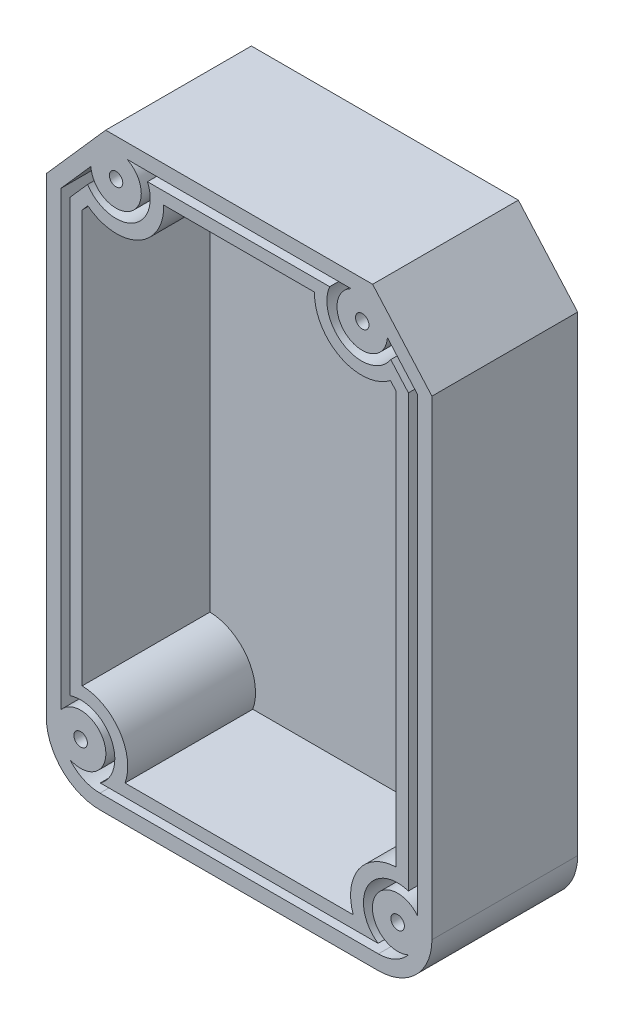
from build123d import *

# Parameters (mm, degrees)
BOSS_EXTRUDE1_DEPTH     = 32.5
CUT_EXTRUDE3_DEPTH      = 1675.790348595
CUT_EXTRUDE3_DEPTH_BACK = 28.5
SKETCH32_R              = 5.625
SKETCH32_R_2            = 1.5
BOSS_EXTRUDE5_DEPTH     = 28.5
CUT_EXTRUDE15_START     = -4
SKETCH33_R              = 1.5
CUT_EXTRUDE15_DEPTH     = 4
BOSS_EXTRUDE6_DEPTH     = 28.5


with BuildPart() as part:
    # Sketch1 → Boss-Extrude1 (new body)
    with BuildSketch(Plane.XY):
        with BuildLine():
            Line((-1355.694223154, -734.745915254), (-1355.694223154, -839.745915254))
            ThreePointArc((-1355.694223154, -839.745915254), (-1359.194004226, -848.195134183), (-1367.643223154, -851.694915254))
            Line((-1367.643223154, -851.694915254), (-1429.745223154, -851.694915254))
            ThreePointArc((-1429.745223154, -851.694915254), (-1438.194442083, -848.195134183), (-1441.694223154, -839.745915254))
            Line((-1441.694223154, -839.745915254), (-1441.694223154, -734.745915254))
            Line((-1441.694223154, -734.745915254), (-1428.465466599, -719.745915254))
            Line((-1428.465466599, -719.745915254), (-1368.92297971, -719.745915254))
            Line((-1368.92297971, -719.745915254), (-1355.694223154, -734.745915254))
        make_face()
    extrude(amount=BOSS_EXTRUDE1_DEPTH)

    # Sketch2 → Cut-Extrude3 (cut, two sides: drawn at the far end of the back side and taken through both)
    with BuildSketch(Plane.XY.offset(32.5).offset(-CUT_EXTRUDE3_DEPTH_BACK)):
        with BuildLine():
            Line((-1358.944223154, -735.974299792), (-1370.390082456, -722.995915254))
            Line((-1370.390082456, -722.995915254), (-1426.998363853, -722.995915254))
            Line((-1426.998363853, -722.995915254), (-1438.444223154, -735.974299792))
            Line((-1438.444223154, -735.974299792), (-1438.444223154, -839.745915254))
            ThreePointArc((-1438.444223154, -839.745915254), (-1435.896345044, -845.897037144), (-1429.745223154, -848.444915254))
            Line((-1429.745223154, -848.444915254), (-1367.643223154, -848.444915254))
            ThreePointArc((-1367.643223154, -848.444915254), (-1361.492101265, -845.897037144), (-1358.944223154, -839.745915254))
            Line((-1358.944223154, -839.745915254), (-1358.944223154, -735.974299792))
        make_face()
    extrude(amount=CUT_EXTRUDE3_DEPTH + CUT_EXTRUDE3_DEPTH_BACK, mode=Mode.SUBTRACT)

    # Sketch32 → Boss-Extrude5 (add)
    # profile 1 of 4: a face of its own
    with BuildSketch(Plane.XY.offset(4)):
        with Locations((-1426.148363853, -728.045915254)):
            Circle(SKETCH32_R)
        with Locations(Location((-1426.148363853, -728.045915254, 0), (0, 0, 180))):
            Circle(SKETCH32_R_2, mode=Mode.SUBTRACT)
    # profile 2 of 4: a face of its own
    with BuildSketch(Plane.XY.offset(4)):
        with Locations((-1371.240082456, -728.045915254)):
            Circle(SKETCH32_R)
        with Locations(Location((-1371.240082456, -728.045915254, 0), (0, 0, 180))):
            Circle(SKETCH32_R_2, mode=Mode.SUBTRACT)
    # profile 3 of 4: a face of its own
    with BuildSketch(Plane.XY.offset(4)):
        with Locations((-1434.045223154, -840.194915254)):
            Circle(SKETCH32_R)
        with Locations(Location((-1434.045223154, -840.194915254, 0), (0, 0, 180))):
            Circle(SKETCH32_R_2, mode=Mode.SUBTRACT)
    # profile 4 of 4: a face of its own
    with BuildSketch(Plane.XY.offset(4)):
        with Locations((-1363.343223154, -840.194915254)):
            Circle(SKETCH32_R)
        with Locations(Location((-1363.343223154, -840.194915254, 0), (0, 0, 180))):
            Circle(SKETCH32_R_2, mode=Mode.SUBTRACT)
    extrude(amount=BOSS_EXTRUDE5_DEPTH)

    # Sketch33 → Cut-Extrude15 (cut)
    with BuildSketch(Plane.XY.offset(4).offset(CUT_EXTRUDE15_START)):
        with Locations(Location((-1363.343223154, -840.194915254, 0), (0, 0, 180))):
            Circle(SKETCH33_R)
        with Locations(Location((-1434.045223154, -840.194915254, 0), (0, 0, 180))):
            Circle(SKETCH33_R)
        with Locations(Location((-1426.148363853, -728.045915254, 0), (0, 0, 180))):
            Circle(SKETCH33_R)
        with Locations(Location((-1371.240082456, -728.045915254, 0), (0, 0, 180))):
            Circle(SKETCH33_R)
    extrude(amount=CUT_EXTRUDE15_DEPTH, mode=Mode.SUBTRACT)


with BuildPart() as body_2:
    # Sketch34 → Boss-Extrude6 (new body)
    with BuildSketch(Plane.XY.offset(4)):
        with BuildLine():
            Line((-1429.677371852, -846.444915254), (-1429.46264746, -846.444915254))
            Line((-1429.46264746, -846.444915254), (-1367.925798849, -846.444915254))
            Line((-1367.925798849, -846.444915254), (-1367.711074457, -846.444915254))
            ThreePointArc((-1367.711074457, -846.444915254), (-1370.158582994, -836.775632396), (-1360.944223154, -832.957137695))
            Line((-1360.944223154, -832.957137695), (-1360.944223154, -736.730228738))
            Line((-1360.944223154, -736.730228738), (-1364.878806544, -732.268830526))
            ThreePointArc((-1364.878806544, -732.268830526), (-1375.027139432, -734.882628606), (-1378.501833651, -724.995915254))
            Line((-1378.501833651, -724.995915254), (-1419.138777697, -725.044860951))
            ThreePointArc((-1419.138777697, -725.044860951), (-1422.525552734, -734.75530156), (-1432.5025393, -732.260779355))
            Line((-1432.5025393, -732.260779355), (-1432.509639765, -732.268830526))
            Line((-1432.509639765, -732.268830526), (-1436.444223154, -736.730228738))
            Line((-1436.444223154, -736.730228738), (-1436.444223154, -832.957137695))
            ThreePointArc((-1436.444223154, -832.957137695), (-1427.229863315, -836.775632396), (-1429.677371852, -846.444915254))
        make_face()
        with BuildLine():
            Line((-1363.694223154, -737.769631038), (-1363.694223154, -829.700783608))
            ThreePointArc((-1363.694223154, -829.700783608), (-1372.01657843, -834.276899687), (-1373.242718091, -843.694915254))
            Line((-1373.242718091, -843.694915254), (-1424.145728218, -843.694915254))
            ThreePointArc((-1424.145728218, -843.694915254), (-1425.371867879, -834.276899687), (-1433.694223154, -829.700783608))
            Line((-1433.694223154, -829.700783608), (-1433.694223154, -737.769631038))
            Line((-1433.694223154, -737.769631038), (-1432.440153254, -736.347649431))
            ThreePointArc((-1432.440153254, -736.347649431), (-1421.253894222, -737.406357088), (-1415.515504499, -727.745915254))
            Line((-1415.515504499, -727.745915254), (-1381.872941809, -727.745915254))
            ThreePointArc((-1381.872941809, -727.745915254), (-1376.134552087, -737.406357088), (-1364.948293055, -736.347649431))
            Line((-1364.948293055, -736.347649431), (-1363.694223154, -737.769631038))
        make_face(mode=Mode.SUBTRACT)
    extrude(amount=BOSS_EXTRUDE6_DEPTH)


solid = Compound([part.part, body_2.part])
